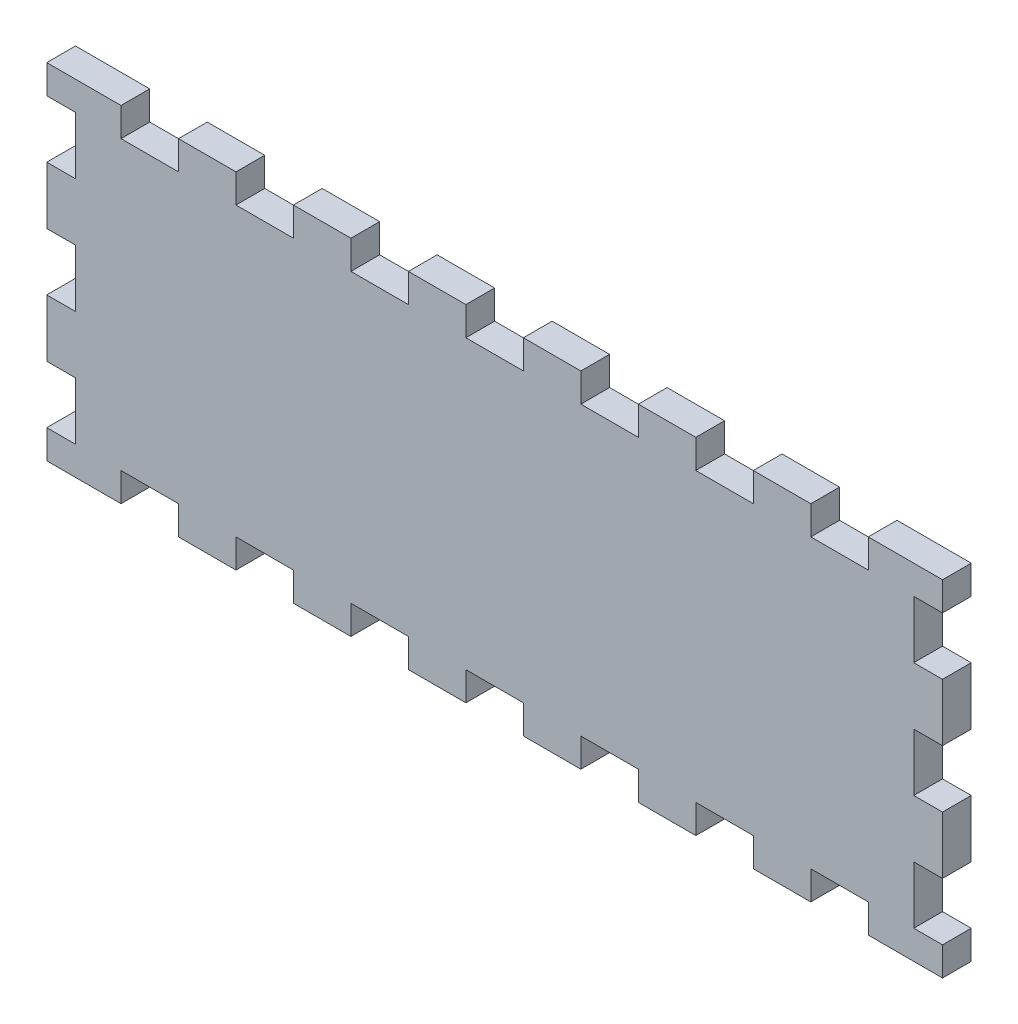
from build123d import *

# Parameters (mm, degrees)
SKETCH1_W           = 6
SKETCH1_H           = 12
BOSS_EXTRUDE3_DEPTH = 6
SKETCH3_W           = 6
SKETCH3_H           = 12
CUT_EXTRUDE1_DEPTH  = 6
SKETCH4_W           = 12
SKETCH4_H           = 6
CUT_EXTRUDE2_DEPTH  = 6


with BuildPart() as part:
    # Sketch1 → Boss-Extrude3 (new body)
    with BuildSketch(Plane.XY):
        Polygon((-93.5, 6), (-93.5, -66), (93.5, -66), (93.5, 6), (78, 6), (78, 0), (66, 0), (66, 6), (54, 6), (54, 0), (42, 0), (42, 6), (30, 6), (30, 0), (18, 0), (18, 6), (6, 6), (6, 0), (-6, 0), (-6, 6), (-18, 6), (-18, 0), (-30, 0), (-30, 6), (-42, 6), (-42, 0), (-54, 0), (-54, 6), (-66, 6), (-66, 0), (-78, 0), (-78, 6), align=None)
        with Locations((90.5, -6)):
            Rectangle(SKETCH1_W, SKETCH1_H)
        with Locations((90.5, -30)):
            Rectangle(SKETCH1_W, SKETCH1_H)
        with Locations((90.5, -54)):
            Rectangle(SKETCH1_W, SKETCH1_H)
    extrude(amount=BOSS_EXTRUDE3_DEPTH)

    # Sketch3 → Cut-Extrude1 (cut)
    with BuildSketch(Plane.XY.offset(6)):
        with Locations((-90.5, -6)):
            Rectangle(SKETCH3_W, SKETCH3_H)
        with Locations((90.5, -6)):
            Rectangle(SKETCH3_W, SKETCH3_H)
        with Locations((90.5, -30)):
            Rectangle(SKETCH3_W, SKETCH3_H)
        with Locations((90.5, -54)):
            Rectangle(SKETCH3_W, SKETCH3_H)
        with Locations((-90.5, -30)):
            Rectangle(SKETCH3_W, SKETCH3_H)
        with Locations((-90.5, -54)):
            Rectangle(SKETCH3_W, SKETCH3_H)
    extrude(amount=-CUT_EXTRUDE1_DEPTH, mode=Mode.SUBTRACT)

    # Sketch4 → Cut-Extrude2 (cut)
    with BuildSketch(Plane.XY.offset(6)):
        with Locations((-72, -63)):
            Rectangle(SKETCH4_W, SKETCH4_H)
        with Locations((-48, -63)):
            Rectangle(SKETCH4_W, SKETCH4_H)
        with Locations((-24, -63)):
            Rectangle(SKETCH4_W, SKETCH4_H)
        with Locations((0, -63)):
            Rectangle(SKETCH4_W, SKETCH4_H)
        with Locations((24, -63)):
            Rectangle(SKETCH4_W, SKETCH4_H)
        with Locations((48, -63)):
            Rectangle(SKETCH4_W, SKETCH4_H)
        with Locations((72, -63)):
            Rectangle(SKETCH4_W, SKETCH4_H)
    extrude(amount=-CUT_EXTRUDE2_DEPTH, mode=Mode.SUBTRACT)


solid = part.part
